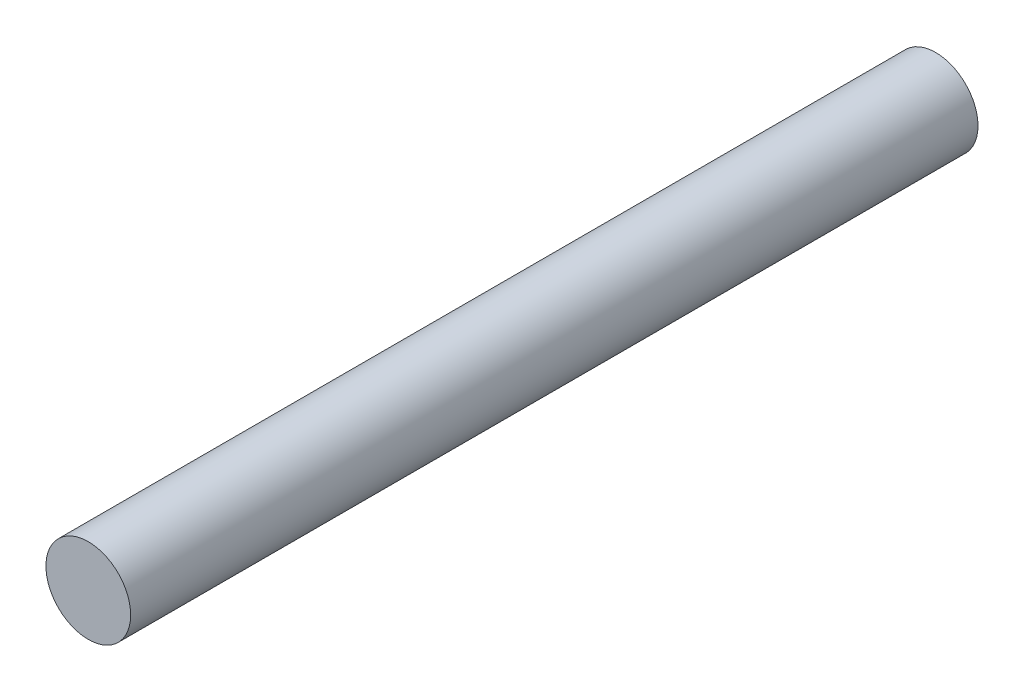
from build123d import *

# Parameters (mm, degrees)
SKETCH1_R           = 3.175
BOSS_EXTRUDE1_DEPTH = 63.5


with BuildPart() as part:
    # Sketch1 → Boss-Extrude1 (new body)
    with BuildSketch(Plane.XY):
        Circle(SKETCH1_R)
    extrude(amount=BOSS_EXTRUDE1_DEPTH)


solid = part.part
